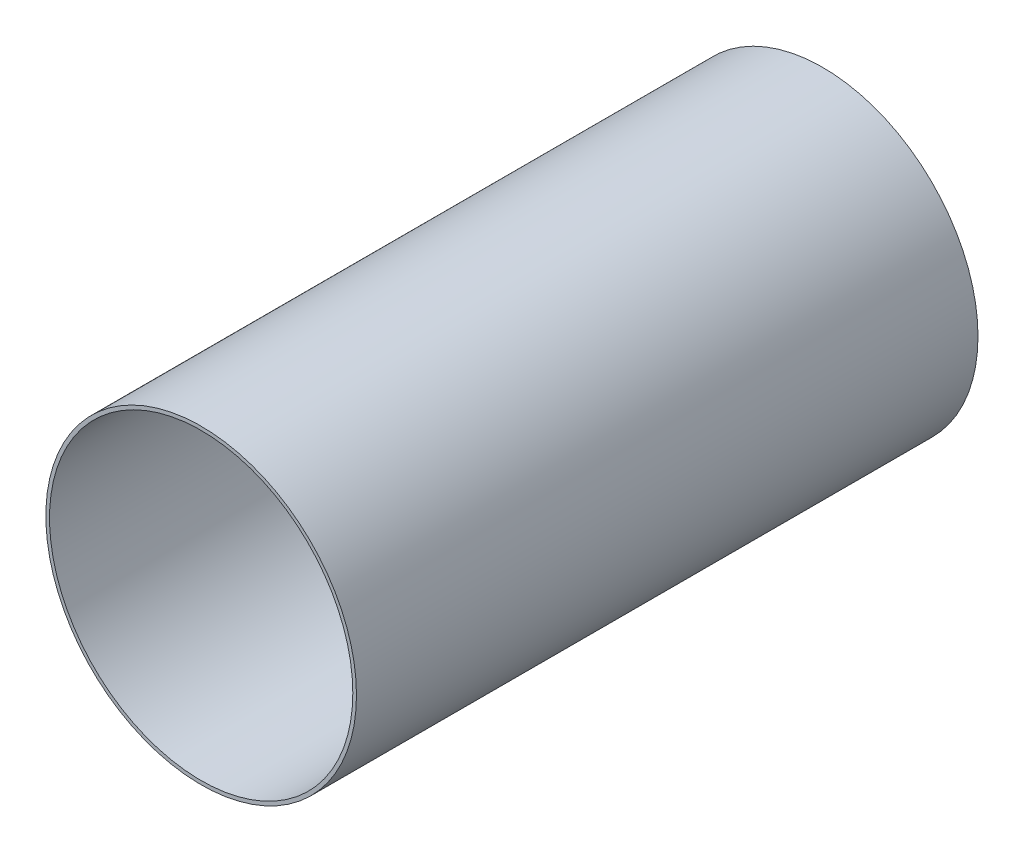
from build123d import *

# Parameters (mm, degrees)
SKETCH1_R           = 63.4746
SKETCH1_R_2         = 61.976
BOSS_EXTRUDE1_DEPTH = 127


with BuildPart() as part:
    # Sketch1 → Boss-Extrude1 (new body, symmetric)
    with BuildSketch(Plane.XY):
        Circle(SKETCH1_R)
        Circle(SKETCH1_R_2, mode=Mode.SUBTRACT)
    extrude(amount=BOSS_EXTRUDE1_DEPTH, both=True)


solid = part.part
